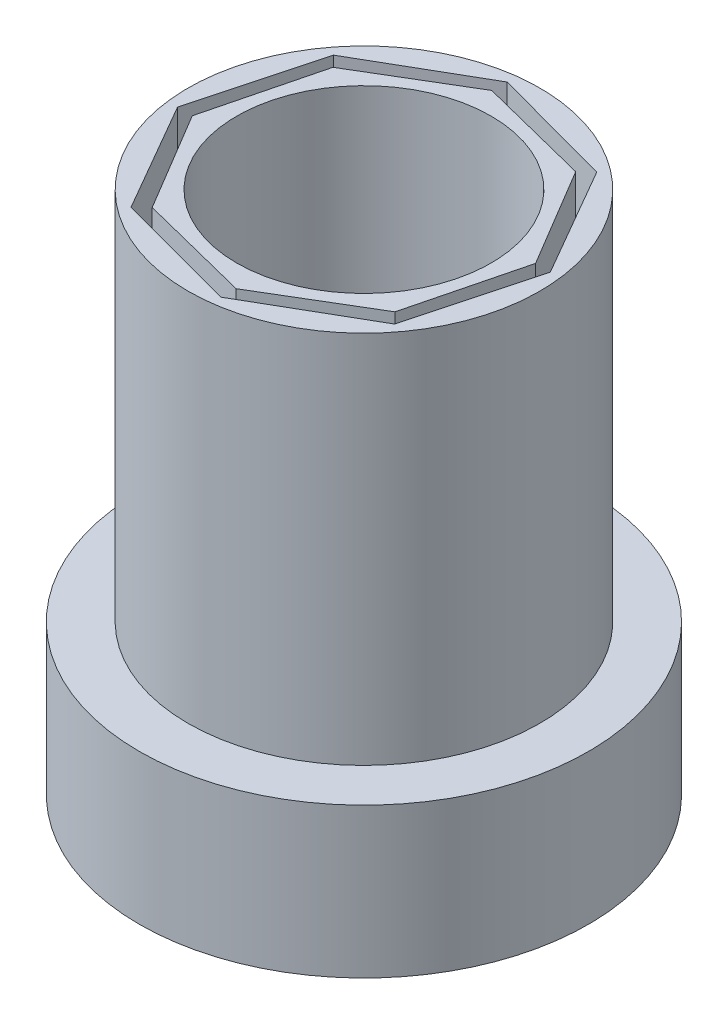
from build123d import *

# Parameters (mm, degrees)
SKETCH1_R           = 17
BOSS_EXTRUDE2_DEPTH = 50
SKETCH3_R           = 23.5
BOSS_EXTRUDE4_DEPTH = 50
SKETCH8_R           = 30
BOSS_EXTRUDE5_DEPTH = 20


with BuildPart() as part:
    # Sketch1 → Boss-Extrude2 (new body)
    with BuildSketch(Plane(origin=(0, 0, 0), x_dir=(1, 0, 0), z_dir=(0, 1, 0))):
        Polygon((16.213203436, -12.071067812), (20, 2.928932188), (12.071067812, 16.213203436), (-2.928932188, 20), (-16.213203436, 12.071067812), (-20, -2.928932188), (-12.071067812, -16.213203436), (2.928932188, -20), align=None)
        Circle(SKETCH1_R, mode=Mode.SUBTRACT)
    extrude(amount=BOSS_EXTRUDE2_DEPTH)



with BuildPart() as body_2:
    # Sketch3 → Boss-Extrude4 (new body)
    with BuildSketch(Plane(origin=(0, 0, 0), x_dir=(1, 0, 0), z_dir=(0, 1, 0))):
        Circle(SKETCH3_R)
        Polygon((-2.890242347, 22), (-17.600059149, 13.512639223), (-22, -2.890242347), (-13.512639223, -17.600059149), (2.890242347, -22), (17.600059149, -13.512639223), (22, 2.890242347), (13.512639223, 17.600059149), align=None, mode=Mode.SUBTRACT)
    extrude(amount=BOSS_EXTRUDE4_DEPTH)


with BuildPart() as part_1:
    add(part.part)

    add(body_2.part)  # Boss-Extrude5 merges body 2
    # Sketch8 → Boss-Extrude5 (add)
    with BuildSketch(Plane(origin=(0, 0, 0), x_dir=(1, 0, 0), z_dir=(0, 1, 0))):
        Circle(SKETCH8_R)
    extrude(amount=-BOSS_EXTRUDE5_DEPTH)


solid = part_1.part
